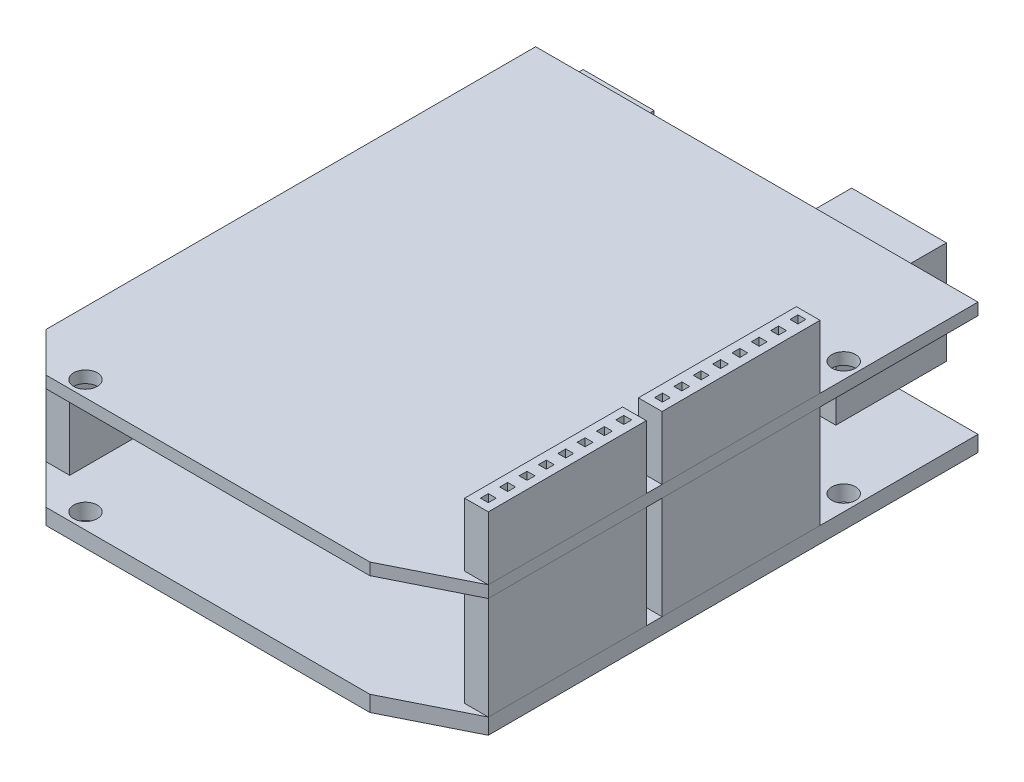
from build123d import *

# Parameters (mm, degrees)
SKETCH_1_R          = 1.5
EXTRUDE_1_DEPTH     = 1.5
SKETCH_2_R          = 1.5
EXTRUDE_2_DEPTH     = 2
SKETCH_3_W          = 3
SKETCH_3_H          = 20
EXTRUDE_4_DEPTH     = 13
EXTRUDE_4_2_DEPTH   = 13
SKETCH_4_W          = 3
SKETCH_4_H          = 20
EXTRUDE_6_DEPTH     = 8
EXTRUDE_6_2_DEPTH   = 8
SKETCH_5_W          = 1
SKETCH_5_H          = 1
CUT_EXTRUDE_1_DEPTH = 5
SKETCH_6_W          = 3
SKETCH_6_H          = 16
EXTRUDE_7_DEPTH     = 13
EXTRUDE_7_2_DEPTH   = 13
SKETCH_7_W          = 12
SKETCH_7_H          = 14
EXTRUDE_8_DEPTH     = 13
CUT_EXTRUDE_2_DEPTH = 10
SKETCH_9_W          = 9
SKETCH_9_H          = 12
EXTRUDE_9_DEPTH     = 13
SKETCH_10_R         = 2.5
CUT_EXTRUDE_3_DEPTH = 10


with BuildPart() as part:
    # Эскиз1 → Бобышка-Вытянуть1 (new body)
    with BuildSketch(Plane(origin=(0, 0, 0), x_dir=(1, 0, 0), z_dir=(0, 1, 0))):
        Polygon((-28, 33.5), (28, 33.5), (28, -28.5), (18, -33.5), (-23, -33.5), (-28, -28.5), align=None)
        with Locations((-20, -31.5)):
            Circle(SKETCH_1_R, mode=Mode.SUBTRACT)
        with Locations((26, 18.5)):
            Circle(SKETCH_1_R, mode=Mode.SUBTRACT)
    extrude(amount=EXTRUDE_1_DEPTH)


with BuildPart() as body_2:
    # Эскиз2 → Бобышка-Вытянуть2 (new body)
    with BuildSketch(Plane(origin=(0, -15, 0), x_dir=(1, 0, 0), z_dir=(0, 1, 0))):
        Polygon((28, 33.5), (-28, 33.5), (-28, -28.5), (-23, -33.5), (18, -33.5), (28, -28.5), align=None)
        with Locations((26, 18.5)):
            Circle(SKETCH_2_R, mode=Mode.SUBTRACT)
        with Locations((-20, -31.5)):
            Circle(SKETCH_2_R, mode=Mode.SUBTRACT)
    extrude(amount=EXTRUDE_2_DEPTH)


with BuildPart() as body_3:
    # Эскиз3 → Бобышка-Вытянуть4 (new body)
    with BuildSketch(Plane(origin=(0, -13, 0), x_dir=(1, 0, 0), z_dir=(0, 1, 0))):
        with Locations((26.5, 3.5)):
            Rectangle(SKETCH_3_W, SKETCH_3_H)
    extrude(amount=EXTRUDE_4_DEPTH)


with BuildPart() as body_4:
    # Эскиз3 → Extrude 4 2 (new body)
    with BuildSketch(Plane(origin=(0, -13, 0), x_dir=(1, 0, 0), z_dir=(0, 1, 0))):
        with Locations((26.5, -18.5)):
            Rectangle(SKETCH_3_W, SKETCH_3_H)
    extrude(amount=EXTRUDE_4_2_DEPTH)


with BuildPart() as body_5:
    # Эскиз4 → Бобышка-Вытянуть6 (new body)
    with BuildSketch(Plane(origin=(0, 1.5, 0), x_dir=(1, 0, 0), z_dir=(0, 1, 0))):
        with Locations((26.5, -18.5)):
            Rectangle(SKETCH_4_W, SKETCH_4_H)
    extrude(amount=EXTRUDE_6_DEPTH)


with BuildPart() as body_6:
    # Эскиз4 → Extrude 6 2 (new body)
    with BuildSketch(Plane(origin=(0, 1.5, 0), x_dir=(1, 0, 0), z_dir=(0, 1, 0))):
        with Locations((26.5, 3.5)):
            Rectangle(SKETCH_4_W, SKETCH_4_H)
    extrude(amount=EXTRUDE_6_2_DEPTH)


with BuildPart() as cut_extrude_1_tool:
    # Эскиз5 → Вырез-Вытянуть1 (new body)
    with BuildSketch(Plane(origin=(0, 9.5, 0), x_dir=(1, 0, 0), z_dir=(0, 1, 0))):
        with Locations((26.5, -27)):
            Rectangle(SKETCH_5_W, SKETCH_5_H)
        with Locations((26.5, -24.55)):
            Rectangle(SKETCH_5_W, SKETCH_5_H)
        with Locations((26.5, -22.1)):
            Rectangle(SKETCH_5_W, SKETCH_5_H)
        with Locations((26.5, -19.65)):
            Rectangle(SKETCH_5_W, SKETCH_5_H)
        with Locations((26.5, -17.2)):
            Rectangle(SKETCH_5_W, SKETCH_5_H)
        with Locations((26.5, -14.75)):
            Rectangle(SKETCH_5_W, SKETCH_5_H)
        with Locations((26.5, -12.3)):
            Rectangle(SKETCH_5_W, SKETCH_5_H)
        with Locations((26.5, -9.85)):
            Rectangle(SKETCH_5_W, SKETCH_5_H)
        with Locations((26.5, -4.95)):
            Rectangle(SKETCH_5_W, SKETCH_5_H)
        with Locations((26.5, -2.5)):
            Rectangle(SKETCH_5_W, SKETCH_5_H)
        with Locations((26.5, -0.05)):
            Rectangle(SKETCH_5_W, SKETCH_5_H)
        with Locations((26.5, 2.4)):
            Rectangle(SKETCH_5_W, SKETCH_5_H)
        with Locations((26.5, 4.85)):
            Rectangle(SKETCH_5_W, SKETCH_5_H)
        with Locations((26.5, 7.3)):
            Rectangle(SKETCH_5_W, SKETCH_5_H)
        with Locations((26.5, 9.75)):
            Rectangle(SKETCH_5_W, SKETCH_5_H)
        with Locations((26.5, 12.2)):
            Rectangle(SKETCH_5_W, SKETCH_5_H)
    extrude(amount=-CUT_EXTRUDE_1_DEPTH)


with BuildPart() as body_5_1:
    add(body_5.part)

    # Вырез-Вытянуть1: cut by cut_extrude_1_tool
    add(cut_extrude_1_tool.part, mode=Mode.SUBTRACT)


with BuildPart() as body_6_1:
    add(body_6.part)

    # Вырез-Вытянуть1: cut by cut_extrude_1_tool
    add(cut_extrude_1_tool.part, mode=Mode.SUBTRACT)


with BuildPart() as body_7:
    # Эскиз6 → Бобышка-Вытянуть7 (new body)
    with BuildSketch(Plane(origin=(0, -13, 0), x_dir=(1, 0, 0), z_dir=(0, 1, 0))):
        with Locations((-26.5, -2.5)):
            Rectangle(SKETCH_6_W, SKETCH_6_H)
    extrude(amount=EXTRUDE_7_DEPTH)


with BuildPart() as body_8:
    # Эскиз6 → Extrude 7 2 (new body)
    with BuildSketch(Plane(origin=(0, -13, 0), x_dir=(1, 0, 0), z_dir=(0, 1, 0))):
        with Locations((-26.5, -20.5)):
            Rectangle(SKETCH_6_W, SKETCH_6_H)
    extrude(amount=EXTRUDE_7_2_DEPTH)


with BuildPart() as body_9:
    # Эскиз7 → Бобышка-Вытянуть8 (new body)
    with BuildSketch(Plane(origin=(0, -13, 0), x_dir=(1, 0, 0), z_dir=(0, 1, 0))):
        with Locations((12, 32.5)):
            Rectangle(SKETCH_7_W, SKETCH_7_H)
    extrude(amount=EXTRUDE_8_DEPTH)

    # Эскиз8 → Вырез-Вытянуть2 (cut)
    with BuildSketch(Plane(origin=(0, 0, -39.5), x_dir=(-1, 0, 0), z_dir=(0, 0, -1))):
        with BuildLine():
            Line((-16, -11), (-8, -11))
            Line((-8, -11), (-8, -4.289726372))
            ThreePointArc((-8, -4.289726372), (-12, -2.289726372), (-16, -4.289726372))
            Line((-16, -4.289726372), (-16, -11))
        make_face()
    extrude(amount=-CUT_EXTRUDE_2_DEPTH, mode=Mode.SUBTRACT)


with BuildPart() as body_10:
    # Эскиз9 → Бобышка-Вытянуть9 (new body)
    with BuildSketch(Plane(origin=(0, -13, 0), x_dir=(1, 0, 0), z_dir=(0, 1, 0))):
        with Locations((-19.5, 29.5)):
            Rectangle(SKETCH_9_W, SKETCH_9_H)
    extrude(amount=EXTRUDE_9_DEPTH)

    # Эскиз10 → Вырез-Вытянуть3 (cut)
    with BuildSketch(Plane(origin=(0, 0, -35.5), x_dir=(-1, 0, 0), z_dir=(0, 0, -1))):
        with Locations((19.5, -6.222141273)):
            Circle(SKETCH_10_R)
    extrude(amount=-CUT_EXTRUDE_3_DEPTH, mode=Mode.SUBTRACT)


solid = Compound([part.part, body_2.part, body_3.part, body_4.part, body_5_1.part, body_6_1.part, body_7.part, body_8.part, body_9.part, body_10.part])
